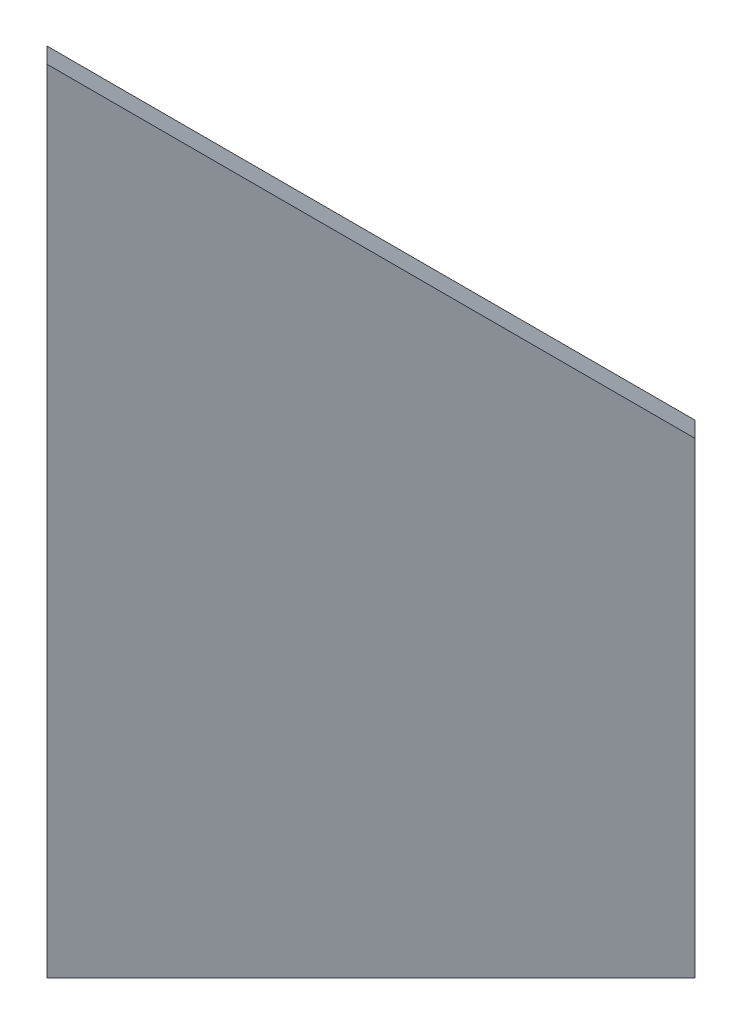
from build123d import *

# Parameters (mm, degrees)
BOSS_EXTRUDE1_DEPTH = 1.5


with BuildPart() as part:
    # Sketch1 → Boss-Extrude1 (new body, symmetric)
    with BuildSketch(Plane(origin=(80.401490288, 0, 80.401490288), x_dir=(0.707106781, 0, -0.707106781), z_dir=(0.707106781, 0, 0.707106781))):
        Polygon((-49.638102576, -48.412903325), (-111.164878, -4.906903198), (-111.164878, -111.164878), (-49.638102576, -111.164878), align=None)
    extrude(amount=BOSS_EXTRUDE1_DEPTH, both=True)


solid = part.part
